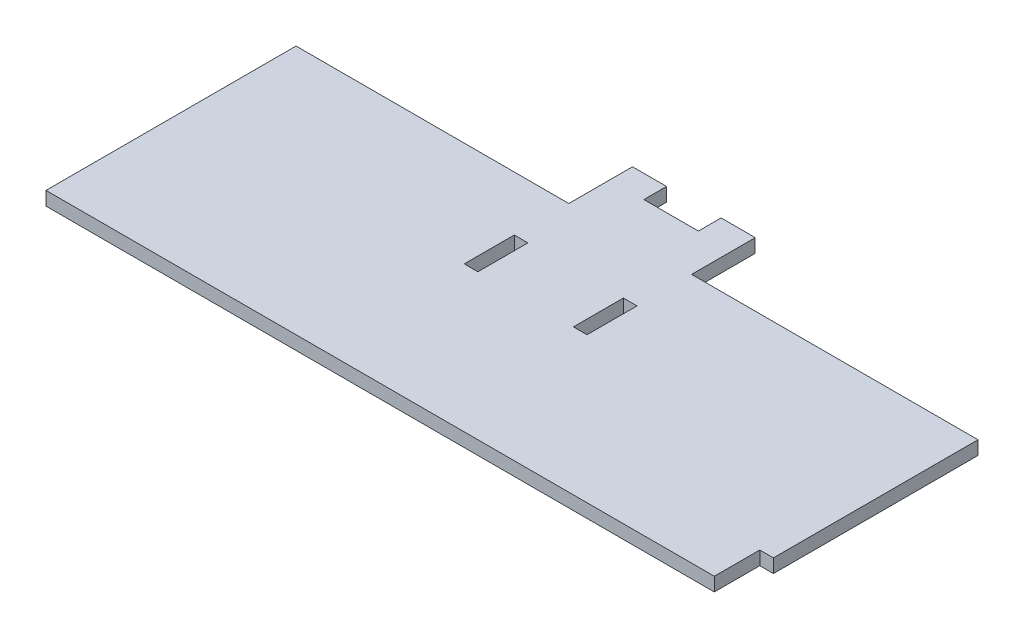
from build123d import *

# Parameters (mm, degrees)
BOSS_EXTRUDE1_DEPTH = 3
SKETCH2_W           = 3
SKETCH2_H           = 11
CUT_EXTRUDE2_DEPTH  = 3
BOSS_EXTRUDE3_DEPTH = 3
SKETCH4_W           = 12
SKETCH4_H           = 10
CUT_EXTRUDE3_DEPTH  = 3


with BuildPart() as part:
    # Sketch1 → Boss-Extrude1 (new body)
    with BuildSketch(Plane(origin=(0, 0, 0), x_dir=(1, 0, 0), z_dir=(0, 1, 0))):
        Polygon((-104.229716691, 61.311583722), (-107.229716691, 61.311583722), (-107.229716691, 51.311583722), (-107.229716691, 6.311583722), (39.770283309, 6.311583722), (39.770283309, 16.311583722), (42.770283309, 16.311583722), (42.770283309, 61.311583722), align=None)
    extrude(amount=BOSS_EXTRUDE1_DEPTH)

    # Sketch2 → Cut-Extrude2 (cut)
    with BuildSketch(Plane(origin=(0, 3, 0), x_dir=(1, 0, 0), z_dir=(0, 1, 0))):
        with Locations((-45.729716691, 43.811583722)):
            Rectangle(SKETCH2_W, SKETCH2_H)
        with Locations((-21.729716691, 43.811583722)):
            Rectangle(SKETCH2_W, SKETCH2_H)
    extrude(amount=-CUT_EXTRUDE2_DEPTH, mode=Mode.SUBTRACT)

    # Sketch3 → Boss-Extrude3 (add)
    with BuildSketch(Plane(origin=(0, 3, 0), x_dir=(1, 0, 0), z_dir=(0, 1, 0))):
        Polygon((-47.229716691, 70.310935644), (-47.229716691, 61.311583722), (-20.229716691, 61.311583722), (-20.229716691, 70.310935644), (-20.229716691, 75.311583722), (-47.229716691, 75.311583722), align=None)
    extrude(amount=-BOSS_EXTRUDE3_DEPTH)

    # Sketch4 → Cut-Extrude3 (cut)
    with BuildSketch(Plane(origin=(0, 3, 0), x_dir=(1, 0, 0), z_dir=(0, 1, 0))):
        with Locations((-33.729716691, 75.311583722)):
            Rectangle(SKETCH4_W, SKETCH4_H)
    extrude(amount=-CUT_EXTRUDE3_DEPTH, mode=Mode.SUBTRACT)


solid = part.part
